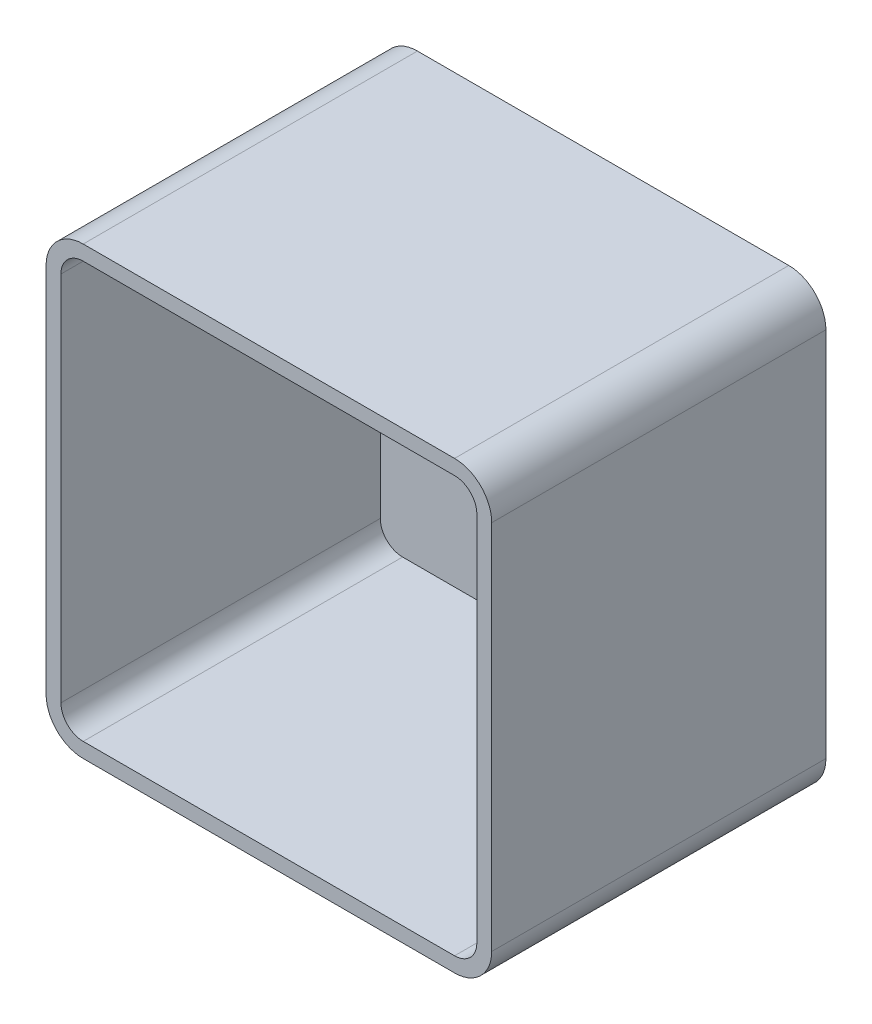
from build123d import *

# Parameters (mm, degrees)
SKETCH1_W           = 120
SKETCH1_H           = 120
BOSS_EXTRUDE1_DEPTH = 90
FILLET1_R           = 10
SHELL1_T            = -4


with BuildPart() as part:
    # Sketch1 → Boss-Extrude1 (new body)
    with BuildSketch(Plane.XY):
        with Locations((60, 60)):
            Rectangle(SKETCH1_W, SKETCH1_H)
    extrude(amount=BOSS_EXTRUDE1_DEPTH)

    # Fillet1
    fillet1_edges = [part.edges().sort_by_distance(p)[0] for p in [
        (0, 120, 45),
        (120, 120, 45),
        (120, 0, 45),
        (0, 0, 45),
    ]]
    fillet(fillet1_edges, radius=FILLET1_R)

    # Shell1
    shell1_openings = [part.faces().sort_by_distance(p)[0] for p in [
        (60, 60, 90),
    ]]
    offset(amount=SHELL1_T, openings=shell1_openings, kind=Kind.INTERSECTION)


solid = part.part
